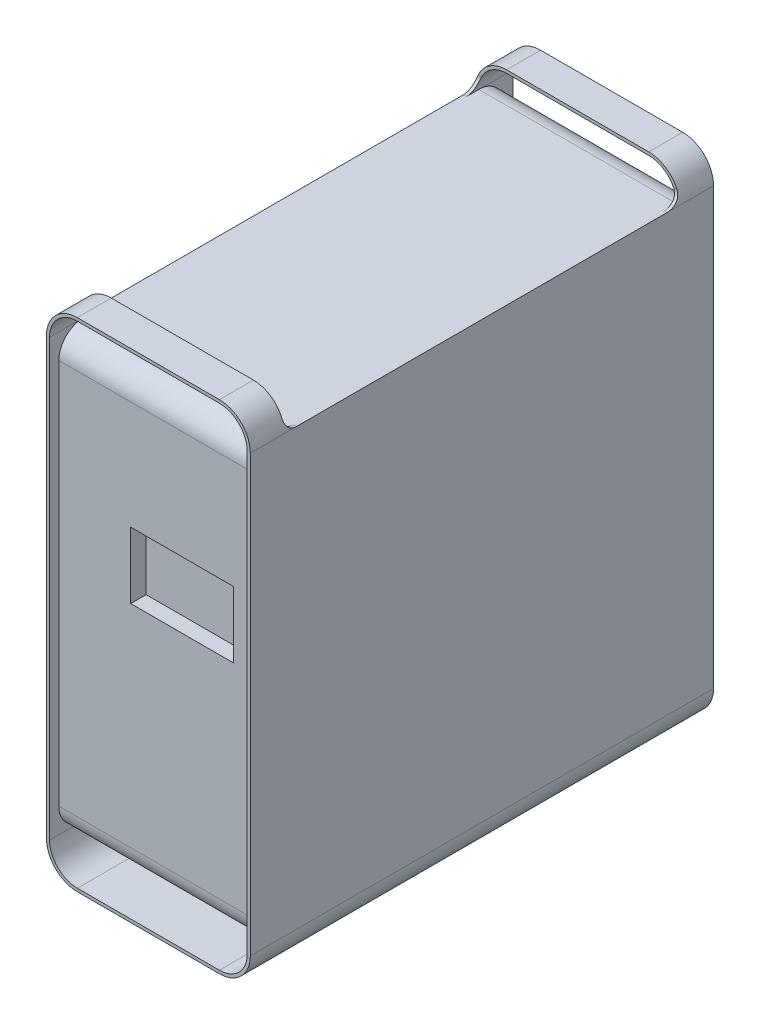
from build123d import *

# Parameters (mm, degrees)
EXTRUDE1_DEPTH     = 476.25
CUT_EXTRUDE1_DEPTH = 210.55
EXTRUDE2_DEPTH     = 203.2
SKETCH5_W          = 105.681165702
SKETCH5_H          = 68.064456382
CUT_EXTRUDE2_DEPTH = 15.875


with BuildPart() as part:
    # Sketch1 → Extrude1 (new body)
    with BuildSketch(Plane.XY):
        with BuildLine():
            Line((-73.025, 255.5875), (73.025, 255.5875))
            ThreePointArc((73.025, 255.5875), (95.475640303, 246.288140303), (104.775, 223.8375))
            Line((104.775, 223.8375), (104.775, -223.8375))
            ThreePointArc((104.775, -223.8375), (95.475640303, -246.288140303), (73.025, -255.5875))
            Line((73.025, -255.5875), (-73.025, -255.5875))
            ThreePointArc((-73.025, -255.5875), (-95.475640303, -246.288140303), (-104.775, -223.8375))
            Line((-104.775, -223.8375), (-104.775, 223.8375))
            ThreePointArc((-104.775, 223.8375), (-95.475640303, 246.288140303), (-73.025, 255.5875))
        make_face()
        with BuildLine():
            Line((-101.6, 223.8375), (-101.6, -223.8375))
            ThreePointArc((-101.6, -223.8375), (-93.230576272, -244.043076272), (-73.025, -252.4125))
            Line((-73.025, -252.4125), (73.025, -252.4125))
            ThreePointArc((73.025, -252.4125), (93.230576272, -244.043076272), (101.6, -223.8375))
            Line((101.6, -223.8375), (101.6, 223.8375))
            ThreePointArc((101.6, 223.8375), (93.230576272, 244.043076272), (73.025, 252.4125))
            Line((73.025, 252.4125), (-73.025, 252.4125))
            ThreePointArc((-73.025, 252.4125), (-93.230576272, 244.043076272), (-101.6, 223.8375))
        make_face(mode=Mode.SUBTRACT)
    extrude(amount=-EXTRUDE1_DEPTH)

    # Sketch2 → Cut-Extrude1 (cut, through all)
    with BuildSketch(Plane(origin=(104.775, 0, 0), x_dir=(0, 0, -1), z_dir=(1, 0, 0))):
        with BuildLine():
            Line((34.925, 236.5375), (34.925, 258.595805141))
            Line((34.925, 258.595805141), (441.325, 258.595805141))
            Line((441.325, 258.595805141), (441.325, 236.5375))
            ThreePointArc((441.325, 236.5375), (437.605256121, 227.557243879), (428.625, 223.8375))
            Line((428.625, 223.8375), (47.625, 223.8375))
            ThreePointArc((47.625, 223.8375), (38.644743879, 227.557243879), (34.925, 236.5375))
        make_face()
    extrude(amount=-CUT_EXTRUDE1_DEPTH, mode=Mode.SUBTRACT)

    # Sketch4 → Extrude2 (add)
    with BuildSketch(Plane(origin=(-101.6, 0, 0), x_dir=(0, 0, -1), z_dir=(1, 0, 0))):
        with BuildLine():
            Line((9.525, 198.4375), (9.525, -198.4375))
            ThreePointArc((9.525, -198.4375), (16.964487758, -216.398012242), (34.925, -223.8375))
            Line((34.925, -223.8375), (441.325, -223.8375))
            ThreePointArc((441.325, -223.8375), (459.285512242, -216.398012242), (466.725, -198.4375))
            Line((466.725, -198.4375), (466.725, 198.4375))
            ThreePointArc((466.725, 198.4375), (459.285512242, 216.398012242), (441.325, 223.8375))
            Line((441.325, 223.8375), (34.925, 223.8375))
            ThreePointArc((34.925, 223.8375), (16.964487758, 216.398012242), (9.525, 198.4375))
        make_face()
    extrude(amount=EXTRUDE2_DEPTH)

    # Sketch5 → Cut-Extrude2 (cut)
    with BuildSketch(Plane.XY.offset(-9.525)):
        with Locations((25.113927792, 52.946208207)):
            Rectangle(SKETCH5_W, SKETCH5_H)
    extrude(amount=-CUT_EXTRUDE2_DEPTH, mode=Mode.SUBTRACT)


solid = part.part
